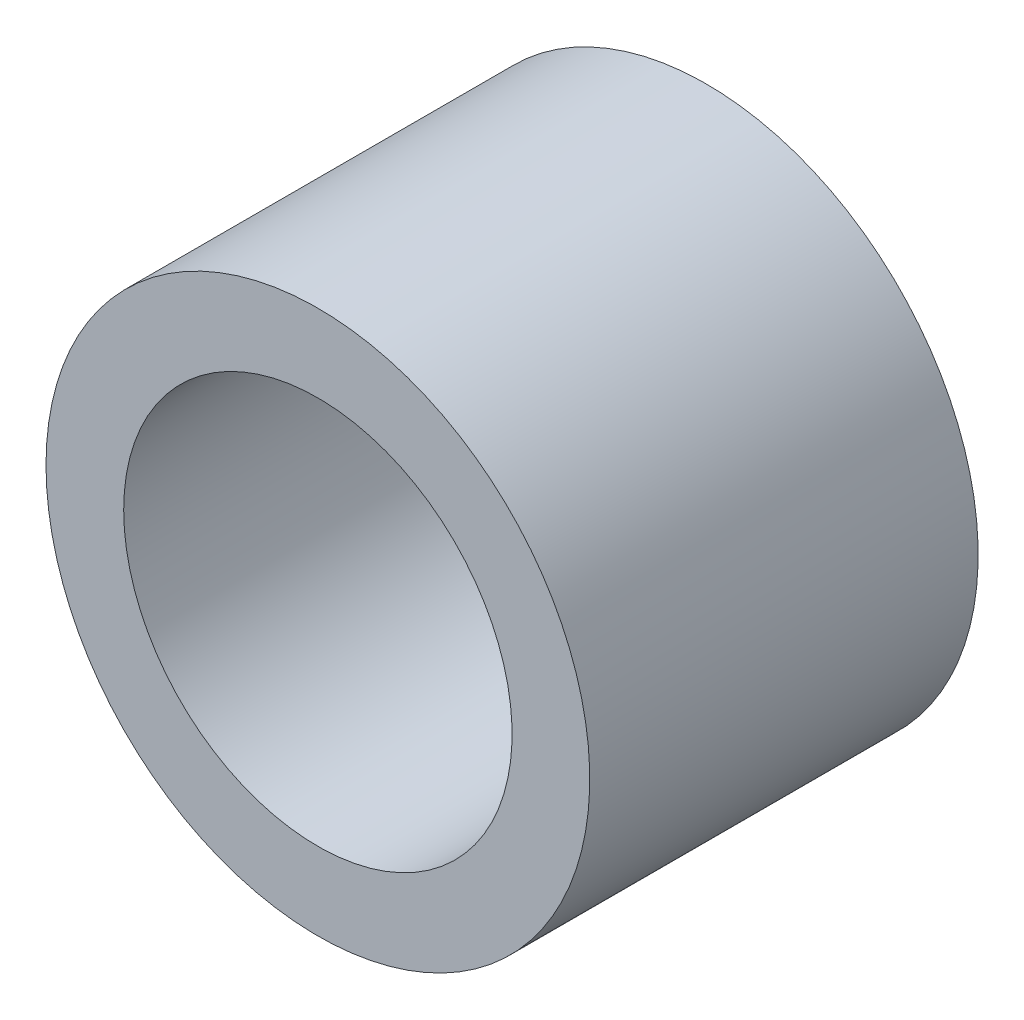
from build123d import *


with BuildPart() as part:
    # Sketch1 → Revolve1 (revolve)
    with BuildSketch(Plane(origin=(0, 0, 0), x_dir=(1, 0, 0), z_dir=(0, 1, 0))):
        Polygon((0, 4), (2, 4), (2, 5), (7, 5), (7, -5), (5, -5), (5, 3), (0, 3), align=None)
    revolve(axis=Axis((0, 0, -12.63647662), (0, 0, 1)))


solid = part.part
